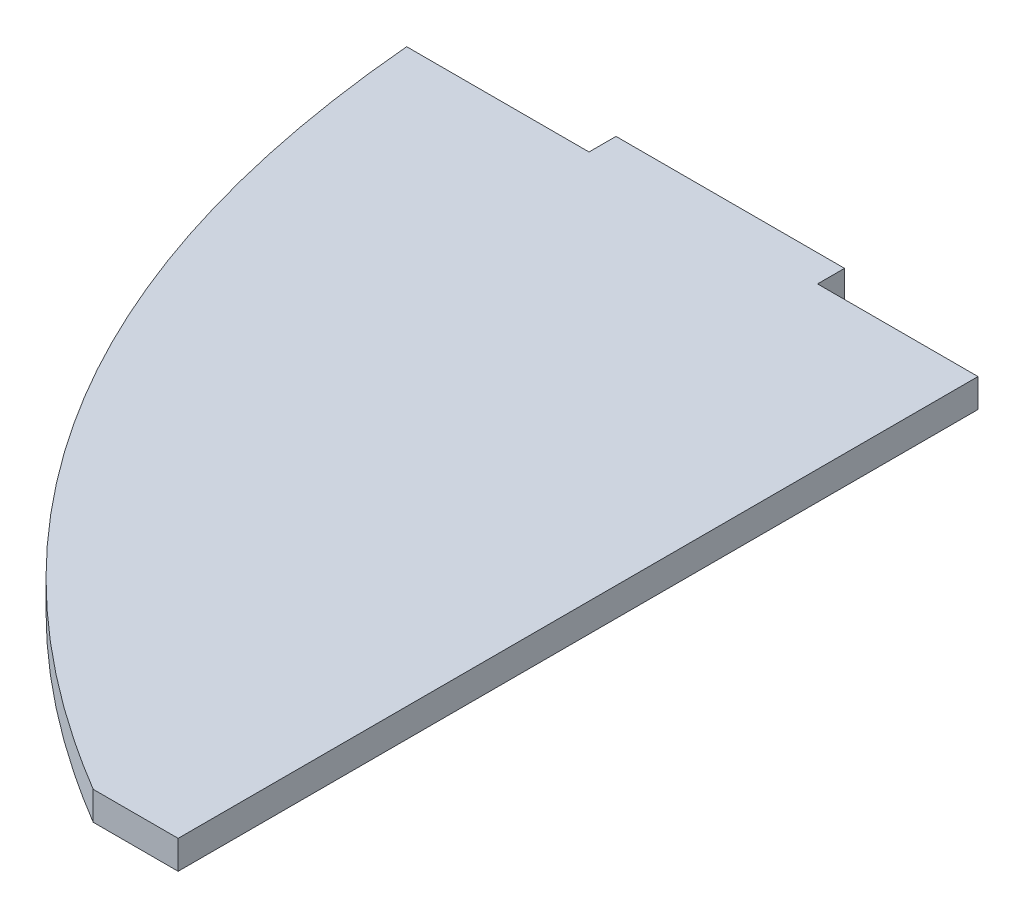
from build123d import *

# Parameters (mm, degrees)
BOSS_EXTRUDE1_DEPTH = 3.175


with BuildPart() as part:
    # Sketch1 → Boss-Extrude1 (new body)
    with BuildSketch(Plane(origin=(0, 0, 0), x_dir=(1, 0, 0), z_dir=(0, 1, 0))):
        with BuildLine():
            Line((36.786206897, 0), (18.953245729, 0))
            Line((18.953245729, 0), (18.953245729, 3))
            Line((18.953245729, 3), (-6.446754271, 3))
            Line((-6.446754271, 3), (-6.446754271, 0))
            Line((-6.446754271, 0), (-26.713793103, 0))
            add(Edge.make_bspline(
                [(27.346845479, -88.9), (-21.534982329, -59.771214116), (-26.713793103, 0)],
                knots=[0, 0, 0, 1, 1, 1], degree=2))
            Line((27.346845479, -88.9), (36.786206897, -88.9))
            Line((36.786206897, -88.9), (36.786206897, 0))
        make_face()
    extrude(amount=-BOSS_EXTRUDE1_DEPTH)


solid = part.part
